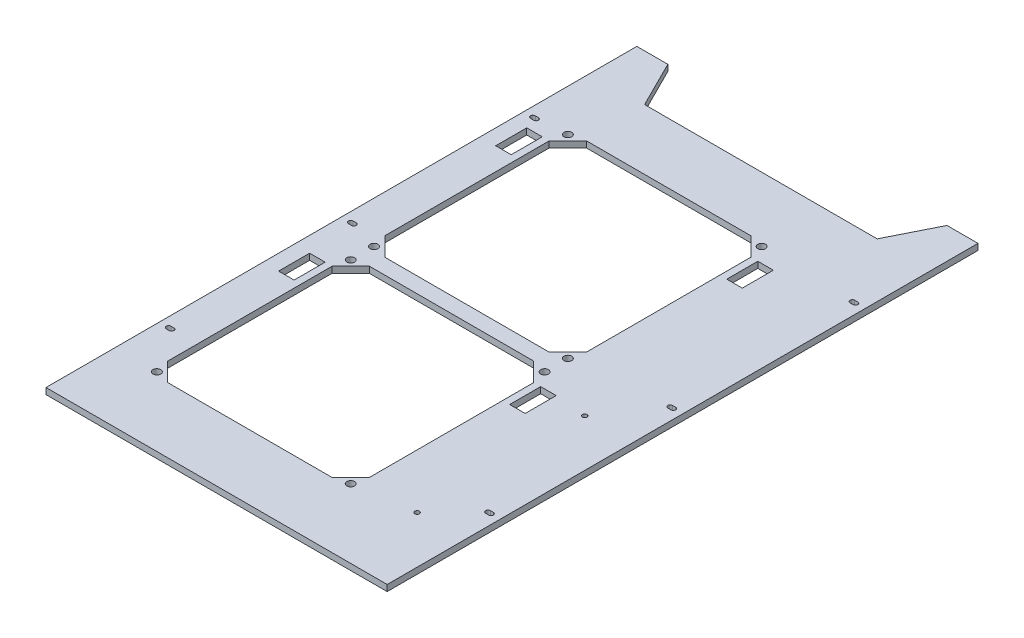
from build123d import *

# Parameters (mm, degrees)
SKETCH_1_R      = 1.5
SKETCH_1_R_2    = 2.5
SKETCH_1_W      = 10
SKETCH_1_H      = 20
EXTRUDE_1_DEPTH = 4


with BuildPart() as part:
    # 草圖1 → 填料-伸長1 (new body)
    with BuildSketch(Plane(origin=(0, 4, 0), x_dir=(1, 0, 0), z_dir=(0, 1, 0))):
        Polygon((-75, 160.5), (-90, 190.5), (-110, 190.5), (-110, -190.5), (110, -190.5), (110, 190.5), (90, 190.5), (75, 160.5), align=None)
        with Locations((79.5, -32.62)):
            Circle(SKETCH_1_R, mode=Mode.SUBTRACT)
        with Locations((79.5, -140.62)):
            Circle(SKETCH_1_R, mode=Mode.SUBTRACT)
        with Locations((-83, -6)):
            Circle(SKETCH_1_R_2, mode=Mode.SUBTRACT)
        with Locations((42, -21)):
            Circle(SKETCH_1_R_2, mode=Mode.SUBTRACT)
        with Locations((42, -146)):
            Circle(SKETCH_1_R_2, mode=Mode.SUBTRACT)
        with Locations((-83, -146)):
            Circle(SKETCH_1_R_2, mode=Mode.SUBTRACT)
        with Locations((-83, 119)):
            Circle(SKETCH_1_R_2, mode=Mode.SUBTRACT)
        with Locations((42, -6)):
            Circle(SKETCH_1_R_2, mode=Mode.SUBTRACT)
        with Locations((-83, -21)):
            Circle(SKETCH_1_R_2, mode=Mode.SUBTRACT)
        with Locations((42, 119)):
            Circle(SKETCH_1_R_2, mode=Mode.SUBTRACT)
        with BuildLine():
            Line((-104, 1.5), (-102, 1.5))
            ThreePointArc((-102, 1.5), (-100.5, 0), (-102, -1.5))
            Line((-102, -1.5), (-104, -1.5))
            ThreePointArc((-104, -1.5), (-105.5, 0), (-104, 1.5))
        make_face(mode=Mode.SUBTRACT)
        with BuildLine():
            Line((102, -116), (104, -116))
            ThreePointArc((104, -116), (105.5, -117.5), (104, -119))
            Line((104, -119), (102, -119))
            ThreePointArc((102, -119), (100.5, -117.5), (102, -116))
        make_face(mode=Mode.SUBTRACT)
        with BuildLine():
            Line((102, 1.5), (104, 1.5))
            ThreePointArc((104, 1.5), (105.5, 0), (104, -1.5))
            Line((104, -1.5), (102, -1.5))
            ThreePointArc((102, -1.5), (100.5, 0), (102, 1.5))
        make_face(mode=Mode.SUBTRACT)
        with BuildLine():
            Line((102, 119), (104, 119))
            ThreePointArc((104, 119), (105.5, 117.5), (104, 116))
            Line((104, 116), (102, 116))
            ThreePointArc((102, 116), (100.5, 117.5), (102, 119))
        make_face(mode=Mode.SUBTRACT)
        with BuildLine():
            Line((-104, -116), (-102, -116))
            ThreePointArc((-102, -116), (-100.5, -117.5), (-102, -119))
            Line((-102, -119), (-104, -119))
            ThreePointArc((-104, -119), (-105.5, -117.5), (-104, -116))
        make_face(mode=Mode.SUBTRACT)
        with BuildLine():
            Line((-104, 119), (-102, 119))
            ThreePointArc((-102, 119), (-100.5, 117.5), (-102, 116))
            Line((-102, 116), (-104, 116))
            ThreePointArc((-104, 116), (-105.5, 117.5), (-104, 119))
        make_face(mode=Mode.SUBTRACT)
        Polygon((-85.5, 3.5), (-85.5, 109.5), (-73.5, 121.5), (32.5, 121.5), (44.5, 109.5), (44.5, 3.5), (32.5, -8.5), (-73.5, -8.5), align=None, mode=Mode.SUBTRACT)
        Polygon((-85.5, -30.5), (-73.5, -18.5), (32.5, -18.5), (44.5, -30.5), (44.5, -136.5), (32.5, -148.5), (-73.5, -148.5), (-85.5, -136.5), align=None, mode=Mode.SUBTRACT)
        with Locations((-95, 99.5)):
            Rectangle(SKETCH_1_W, SKETCH_1_H, mode=Mode.SUBTRACT)
        with Locations((54, 99.5)):
            Rectangle(SKETCH_1_W, SKETCH_1_H, mode=Mode.SUBTRACT)
        with Locations((54, -40.5)):
            Rectangle(SKETCH_1_W, SKETCH_1_H, mode=Mode.SUBTRACT)
        with Locations((-95, -40.5)):
            Rectangle(SKETCH_1_W, SKETCH_1_H, mode=Mode.SUBTRACT)
    extrude(amount=-EXTRUDE_1_DEPTH)


solid = part.part
